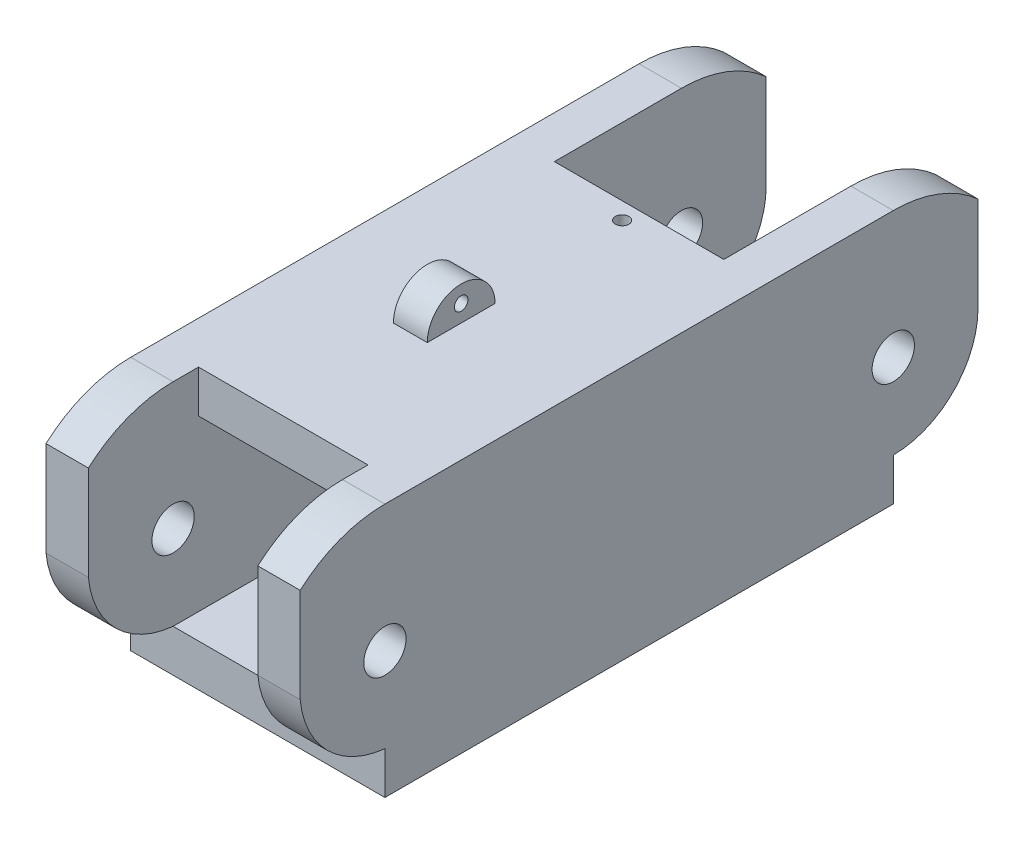
from build123d import *

# Parameters (mm, degrees)
SKETCH1_W           = 19.05
SKETCH1_H           = 57.15
BOSS_EXTRUDE1_DEPTH = 19.05
SKETCH2_W           = 12.7
SKETCH2_H           = 12.7
CUT_EXTRUDE1_DEPTH  = 76.2
SKETCH3_W           = 2.54
SKETCH3_H           = 5.08
BOSS_EXTRUDE2_DEPTH = 2.54
SKETCH4_R           = 0.508
SKETCH4_R_2         = 1.5875
CUT_EXTRUDE2_DEPTH  = 19.05
SKETCH7_R           = 0.508
CUT_EXTRUDE3_DEPTH  = 12.7
SKETCH8_W           = 12.7
SKETCH8_H           = 9.525
CUT_EXTRUDE4_DEPTH  = 25.4
SKETCH11_R          = 1.5875
CUT_EXTRUDE6_DEPTH  = 19.05
SKETCH12_W          = 12.7
SKETCH12_H          = 30.970960978
CUT_EXTRUDE7_DEPTH  = 3.81
SKETCH13_W          = 12.7
SKETCH13_H          = 19.463069007
CUT_EXTRUDE8_DEPTH  = 3.81
CUT_EXTRUDE9_DEPTH  = 19.05


with BuildPart() as part:
    # Sketch1 → Boss-Extrude1 (new body)
    with BuildSketch(Plane(origin=(0, 0, 0), x_dir=(1, 0, 0), z_dir=(0, 1, 0))):
        with Locations((9.525, 28.575)):
            Rectangle(SKETCH1_W, SKETCH1_H)
    extrude(amount=BOSS_EXTRUDE1_DEPTH)

    # Sketch2 → Cut-Extrude1 (cut)
    with BuildSketch(Plane.XY):
        with Locations((9.525, 9.525)):
            Rectangle(SKETCH2_W, SKETCH2_H)
    extrude(amount=-CUT_EXTRUDE1_DEPTH, mode=Mode.SUBTRACT)

    # Sketch3 → Boss-Extrude2 (add)
    with BuildSketch(Plane(origin=(0, 19.05, 0), x_dir=(1, 0, 0), z_dir=(0, 1, 0))):
        with Locations((8.89, 24.13)):
            Rectangle(SKETCH3_W, SKETCH3_H)
    extrude(amount=BOSS_EXTRUDE2_DEPTH)

    # Sketch4 → Cut-Extrude2 (cut)
    with BuildSketch(Plane(origin=(0, 0, 0), x_dir=(0, 0, -1), z_dir=(1, 0, 0))):
        with Locations((24.13, 20.32)):
            Circle(SKETCH4_R)
        with Locations((9.525, 9.525)):
            Circle(SKETCH4_R_2)
        with BuildLine():
            ThreePointArc((26.67, 19.05), (24.13, 24.78976855), (21.59, 19.05))
            add(Edge.make_bspline(
                [(26.67, 19.05), (26.67, 21.59), (24.13, 21.59), (21.59, 21.59), (21.59, 19.05)],
                knots=[3.141592654, 3.141592654, 3.141592654, 4.71238898, 4.71238898, 6.283185307, 6.283185307, 6.283185307], degree=2, weights=[1, 0.707106781, 1, 0.707106781, 1]))
        make_face()
        with BuildLine():
            ThreePointArc((9.525, 19.05), (0, 9.525), (9.525, 0))
            ThreePointArc((9.525, 0), (-29.420443119, 9.525), (9.525, 19.05))
        make_face()
    extrude(amount=CUT_EXTRUDE2_DEPTH, mode=Mode.SUBTRACT)

    # Sketch7 → Cut-Extrude3 (cut)
    with BuildSketch(Plane(origin=(0, 19.05, 0), x_dir=(1, 0, 0), z_dir=(0, 1, 0))):
        with Locations((9.525, 36.83)):
            Circle(SKETCH7_R)
        Polygon((3.175, 0), (3.175, 11.43), (6.35, 11.43), (12.7, 11.43), (15.875, 11.43), (15.875, 0), align=None)
    extrude(amount=-CUT_EXTRUDE3_DEPTH, mode=Mode.SUBTRACT)

    # Sketch8 → Cut-Extrude4 (cut)
    with BuildSketch(Plane(origin=(0, 19.05, 0), x_dir=(1, 0, 0), z_dir=(0, 1, 0))):
        with Locations((9.525, 4.7625)):
            Rectangle(SKETCH8_W, SKETCH8_H)
    extrude(amount=-CUT_EXTRUDE4_DEPTH, mode=Mode.SUBTRACT)

    # Sketch11 → Cut-Extrude6 (cut)
    with BuildSketch(Plane(origin=(0, 0, 0), x_dir=(0, 0, -1), z_dir=(1, 0, 0))):
        with Locations((47.625, 9.525)):
            Circle(SKETCH11_R)
        with BuildLine():
            ThreePointArc((47.625, 0), (57.15, 9.525), (47.625, 19.05))
            ThreePointArc((47.625, 19.05), (63.905355935, 9.525), (47.625, 0))
        make_face()
    extrude(amount=CUT_EXTRUDE6_DEPTH, mode=Mode.SUBTRACT)

    # Sketch12 → Cut-Extrude7 (cut)
    with BuildSketch(Plane(origin=(0, 19.05, 0), x_dir=(1, 0, 0), z_dir=(0, 1, 0))):
        with Locations((9.525, 53.585480489)):
            Rectangle(SKETCH12_W, SKETCH12_H)
    extrude(amount=-CUT_EXTRUDE7_DEPTH, mode=Mode.SUBTRACT)

    # Sketch13 → Cut-Extrude8 (cut)
    with BuildSketch(Plane(origin=(0, 0, 0), x_dir=(1, 0, 0), z_dir=(0, 1, 0))):
        with Locations((9.525, 57.356534504)):
            Rectangle(SKETCH13_W, SKETCH13_H)
    extrude(amount=CUT_EXTRUDE8_DEPTH, mode=Mode.SUBTRACT)

    # Sketch14 → Cut-Extrude9 (cut)
    with BuildSketch(Plane(origin=(0, 0, 0), x_dir=(0, 0, -1), z_dir=(1, 0, 0))):
        with BuildLine():
            Line((9.525, 0), (9.525, 3.175))
            ThreePointArc((9.525, 3.175), (5.21507822, 5.21507822), (3.175, 9.525))
            Line((3.175, 9.525), (3.175, 18.741336737))
            Line((3.175, 18.741336737), (-3.728591213, 9.978700773))
            Line((-3.728591213, 9.978700773), (-2.544461104, 0))
            Line((-2.544461104, 0), (9.525, 0))
        make_face()
        with BuildLine():
            Line((47.625, 0), (47.625, 3.175))
            ThreePointArc((47.625, 3.175), (52.115128061, 5.034871939), (53.975, 9.525))
            Line((53.975, 9.525), (53.975, 20.201145039))
            Line((53.975, 20.201145039), (59.422737854, 9.525))
            Line((59.422737854, 9.525), (58.062916797, -0.332636104))
            Line((58.062916797, -0.332636104), (47.625, 0))
        make_face()
    extrude(amount=CUT_EXTRUDE9_DEPTH, mode=Mode.SUBTRACT)


solid = part.part
